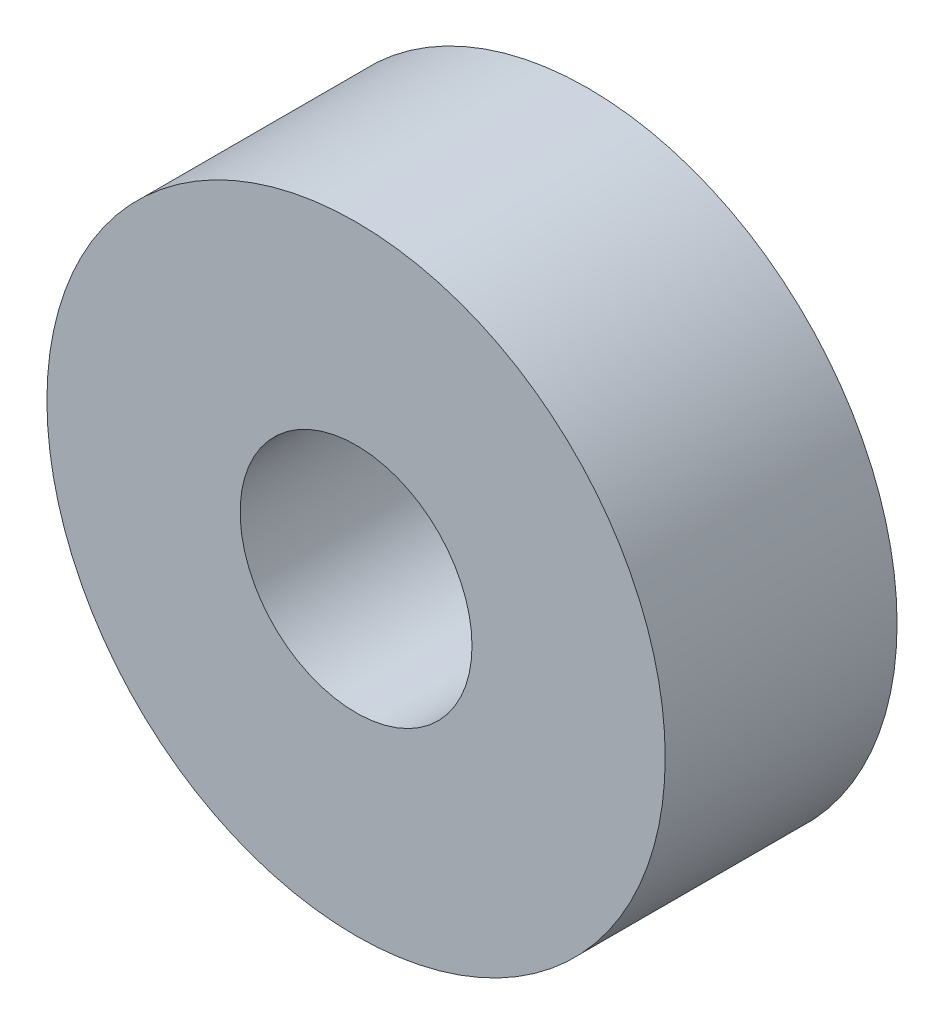
from build123d import *

# Parameters (mm, degrees)
SKETCH1_R           = 16
SKETCH1_R_2         = 6
BOSS_EXTRUDE1_DEPTH = 12


with BuildPart() as part:
    # Sketch1 → Boss-Extrude1 (new body)
    with BuildSketch(Plane.XY):
        Circle(SKETCH1_R)
        Circle(SKETCH1_R_2, mode=Mode.SUBTRACT)
    extrude(amount=BOSS_EXTRUDE1_DEPTH)


solid = part.part
